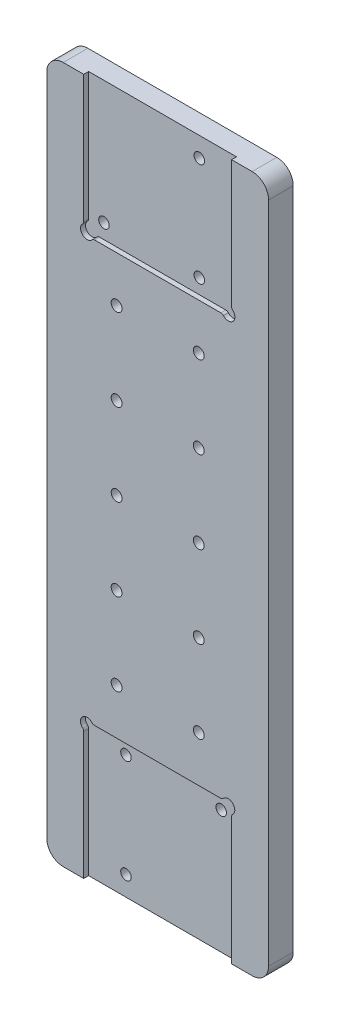
from build123d import *

# Parameters (mm, degrees)
ESTRUSIONE_ESTRUSIONE1_DEPTH                         = 3
ESTRUSIONE_ESTRUSIONE1_DEPTH_BACK                    = 12
TAGLIO_ESTRUSIONE1_DEPTH                             = 3
FORO_LAMATO_PER_VITE_M6_A_TESTA_CILINDRI_D           = 6.4
FORO_LAMATO_PER_VITE_M6_A_TESTA_CILINDRI_CBORE_D     = 11
FORO_LAMATO_PER_VITE_M6_A_TESTA_CILINDRI_CBORE_DEPTH = 6.4
FORO_PER_VITE_M6_2_D                                 = 6.6
RIPETIZIONECIRCOLARE1_COUNT                          = 2


with BuildPart() as part:
    # Schizzo1 → Estrusione-Estrusione1 (new body, two sides)
    with BuildSketch(Plane.XY) as estrusione_estrusione1_sk:
        with BuildLine():
            Line((-57.5, -251.4), (57.5, -251.4))
            ThreePointArc((57.5, -251.4), (64.571067812, -248.471067812), (67.5, -241.4))
            Line((67.5, -241.4), (67.5, 162.5))
            ThreePointArc((67.5, 162.5), (64.571067812, 169.571067812), (57.5, 172.5))
            Line((57.5, 172.5), (-57.5, 172.5))
            ThreePointArc((-57.5, 172.5), (-64.571067812, 169.571067812), (-67.5, 162.5))
            Line((-67.5, 162.5), (-67.5, -241.4))
            ThreePointArc((-67.5, -241.4), (-64.571067812, -248.471067812), (-57.5, -251.4))
        make_face()
    extrude(amount=ESTRUSIONE_ESTRUSIONE1_DEPTH)
    extrude(estrusione_estrusione1_sk.sketch, amount=-ESTRUSIONE_ESTRUSIONE1_DEPTH_BACK)

    # Schizzo2 → Taglio-Estrusione1 (cut)
    with BuildSketch(Plane.XY.offset(3)):
        with BuildLine():
            Line((-45, -173.872135955), (-45, -251.4))
            Line((-45, -251.4), (45, -251.4))
            Line((45, -251.4), (45, -173.740515135))
            ThreePointArc((45, -173.740515135), (45.167973297, -172.938219578), (45.643678161, -172.270688251))
            ThreePointArc((45.643678161, -172.270688251), (45.715503432, -166.459321985), (39.909116924, -166.710344828))
            ThreePointArc((39.909116924, -166.710344828), (39.228612943, -167.219435305), (38.398158145, -167.4))
            Line((38.398158145, -167.4), (-38.527864045, -167.4))
            ThreePointArc((-38.527864045, -167.4), (-39.344360626, -167.225741858), (-40.01857603, -166.733333333))
            ThreePointArc((-40.01857603, -166.733333333), (-45.828427125, -166.571572875), (-45.666666667, -172.38142397))
            ThreePointArc((-45.666666667, -172.38142397), (-45.174258142, -173.055639374), (-45, -173.872135955))
        make_face()
    taglio_estrusione1 = extrude(amount=-TAGLIO_ESTRUSIONE1_DEPTH, mode=Mode.SUBTRACT)

    # Foro lamato per Vite M6 a testa cilindri (through all)
    with Locations(Plane(origin=(0, 0, -12), x_dir=(-1, 0, 0), z_dir=(0, 0, -1))):
        with Locations((35.696152423, 97.5), (-22.303847577, 97.5), (-22.303847577, 160.5)):
            foro_lamato_per_vite_m6_a_testa_cilindri = CounterBoreHole(FORO_LAMATO_PER_VITE_M6_A_TESTA_CILINDRI_D / 2, FORO_LAMATO_PER_VITE_M6_A_TESTA_CILINDRI_CBORE_D / 2, FORO_LAMATO_PER_VITE_M6_A_TESTA_CILINDRI_CBORE_DEPTH)

    # Foro per Vite M6-2 (through all)
    with Locations(Plane.XY.offset(3)):
        with Locations((-25, -139.45), (25, 60.55), (25, -139.45), (-25, 60.55), (-25, -39.45), (25, -39.45), (-25, -89.45), (25, -89.45), (-25, 10.55), (25, 10.55), (-95.52986496, -268.984692735)):
            Hole(FORO_PER_VITE_M6_2_D / 2)

    # RipetizioneCircolare1: Taglio-Estrusione1, Foro lamato per Vite M6 a testa cilindri ×2 about axis
    ripetizionecircolare1_axis = Axis((0, -39.45, 0), (0, 0, 1))
    add([taglio_estrusione1.rotate(ripetizionecircolare1_axis, i * 360 / RIPETIZIONECIRCOLARE1_COUNT) for i in range(1, RIPETIZIONECIRCOLARE1_COUNT)], mode=Mode.SUBTRACT)
    add([foro_lamato_per_vite_m6_a_testa_cilindri.rotate(ripetizionecircolare1_axis, i * 360 / RIPETIZIONECIRCOLARE1_COUNT) for i in range(1, RIPETIZIONECIRCOLARE1_COUNT)], mode=Mode.SUBTRACT)


solid = part.part
